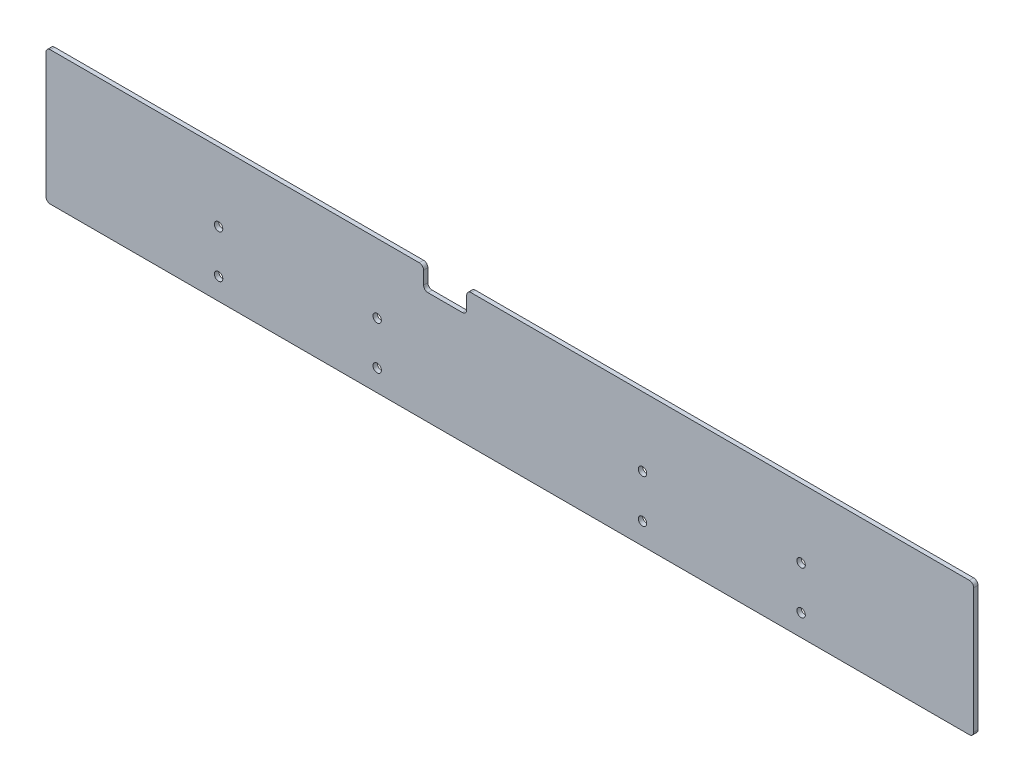
from build123d import *

# Parameters (mm, degrees)
SKETCH1_R           = 1.95
BOSS_EXTRUDE1_DEPTH = 2
FILLET1_R           = 2
SKETCH2_R           = 1.95
CUT_EXTRUDE1_DEPTH  = 10


with BuildPart() as part:
    # Sketch1 → Boss-Extrude1 (new body)
    with BuildSketch(Plane.XY):
        Polygon((-161.905896291, 17.703517588), (73.094103709, 17.703517588), (73.094103709, -44.296482412), (-356.905896291, -44.296482412), (-356.905896291, 17.703517588), (-181.905896291, 17.703517588), (-181.905896291, 7.703517588), (-161.905896291, 7.703517588), align=None)
        with Locations((-80.405896291, -14.296482412)):
            Circle(SKETCH1_R, mode=Mode.SUBTRACT)
        with Locations((-80.405896291, -34.296482412)):
            Circle(SKETCH1_R, mode=Mode.SUBTRACT)
        with Locations((-203.405896291, -14.296482412)):
            Circle(SKETCH1_R, mode=Mode.SUBTRACT)
        with Locations((-203.405896291, -34.296482412)):
            Circle(SKETCH1_R, mode=Mode.SUBTRACT)
    extrude(amount=BOSS_EXTRUDE1_DEPTH)

    # Fillet1
    fillet1_edges = [part.edges().sort_by_distance(p)[0] for p in [
        (-356.905896291, 17.703517588, 1),
        (-181.905896291, 17.703517588, 1),
        (-181.905896291, 7.703517588, 1),
        (-161.905896291, 7.703517588, 1),
        (-161.905896291, 17.703517588, 1),
        (73.094103709, 17.703517588, 1),
        (73.094103709, -44.296482412, 1),
        (-356.905896291, -44.296482412, 1),
    ]]
    fillet(fillet1_edges, radius=FILLET1_R)

    # Sketch2 → Cut-Extrude1 (cut)
    with BuildSketch(Plane.XY.offset(2)):
        with Locations((-276.905896291, -14.296482412)):
            Circle(SKETCH2_R)
        with Locations((-276.905896291, -34.296482412)):
            Circle(SKETCH2_R)
        with Locations((-6.905896291, -14.296482412)):
            Circle(SKETCH2_R)
        with Locations((-6.905896291, -34.296482412)):
            Circle(SKETCH2_R)
    extrude(amount=-CUT_EXTRUDE1_DEPTH, mode=Mode.SUBTRACT)


solid = part.part
